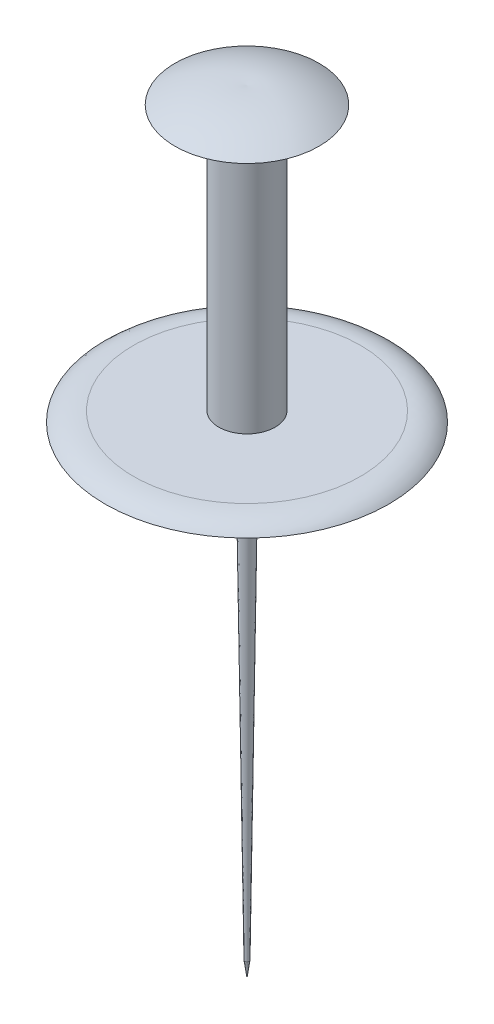
from build123d import *


with BuildPart() as part:
    # Sketch1 → Revolve1 (revolve)
    with BuildSketch(Plane.XY):
        with BuildLine():
            Line((0, 0), (0, 70.258458908))
            add(Edge.make_bspline(
                [(0, 70.258458908), (3.42486489, 70.528708067), (6.542490016, 68.711522876)],
                knots=[0, 0, 0, 1, 1, 1], degree=2))
            Line((6.542490016, 68.711522876), (2.569010768, 68.711522876))
            Line((2.569010768, 68.711522876), (2.569010768, 44.624031208))
            Line((2.569010768, 44.624031208), (10.316772859, 44.624031208))
            add(Edge.make_bspline(
                [(10.316772859, 44.624031208), (12.045144659, 44.645198788), (12.886059681, 43.724390653)],
                knots=[0, 0, 0, 1, 1, 1], degree=2))
            Line((12.886059681, 43.724390653), (0.749314242, 43.724390653))
            Line((0.749314242, 43.724390653), (0.193971896, 1.407170555))
            Line((0.193971896, 1.407170555), (0, 0))
        make_face()
    revolve(axis=Axis((0, 0, 0), (0, 1, 0)))


solid = part.part
